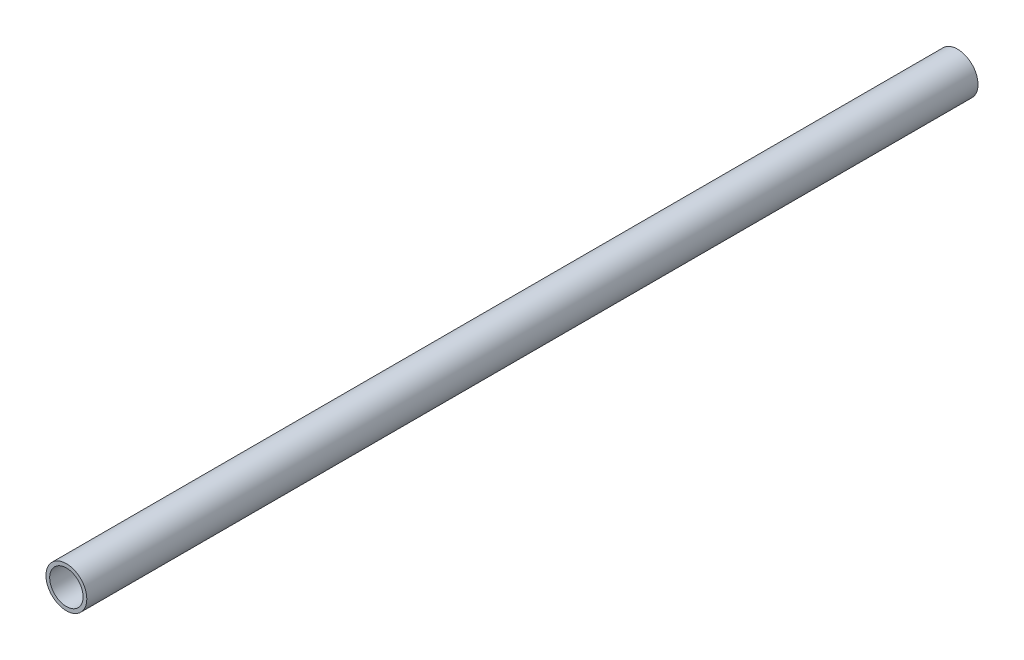
from build123d import *

# Parameters (mm, degrees)
SKETCH_1_R      = 5.5
SKETCH_1_R_2    = 4.5
EXTRUDE_1_DEPTH = 240


with BuildPart() as part:
    # 草图1 → 凸台-拉伸1 (new body)
    with BuildSketch(Plane.XY):
        with Locations((0, 0.015376331)):
            Circle(SKETCH_1_R)
        with Locations((0, 0.015376331)):
            Circle(SKETCH_1_R_2, mode=Mode.SUBTRACT)
    extrude(amount=EXTRUDE_1_DEPTH)


solid = part.part
